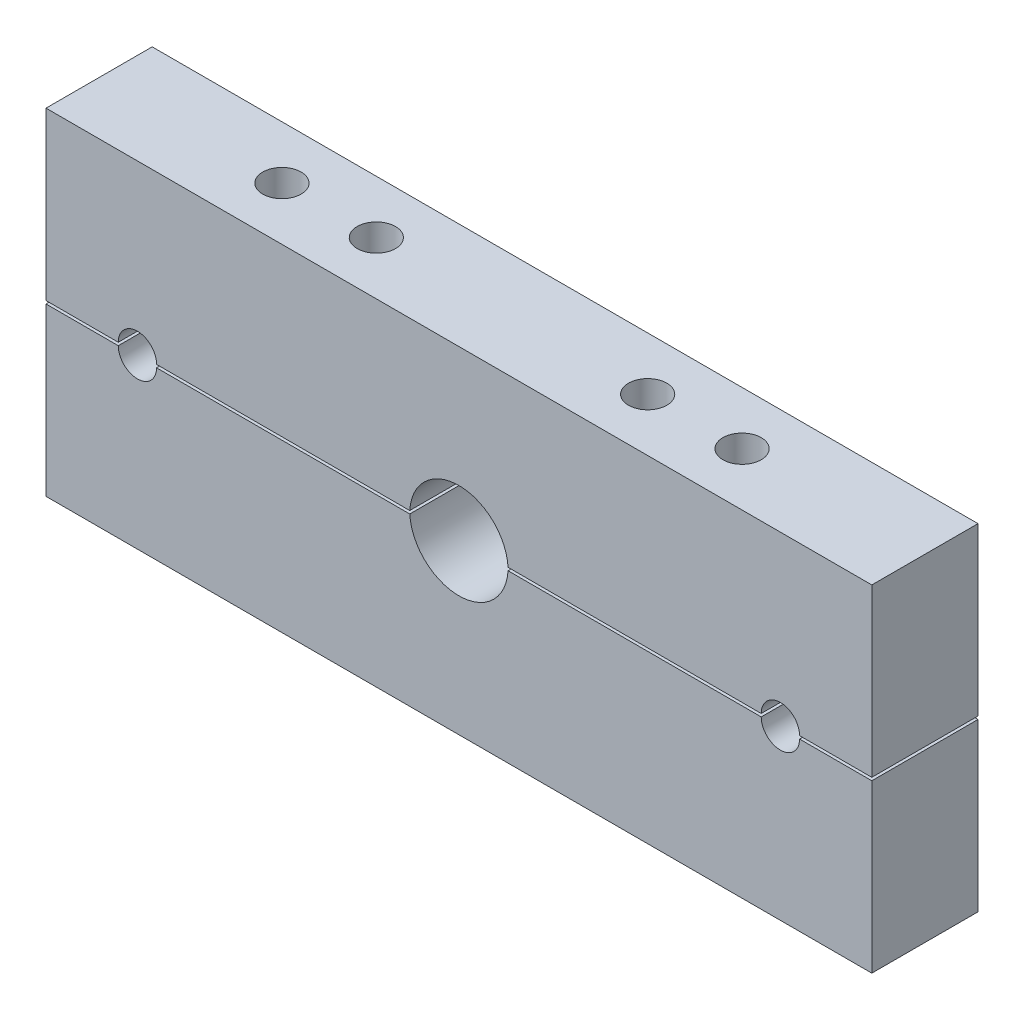
from build123d import *

# Parameters (mm, degrees)
BOSS_EXTRUDE1_DEPTH = 36
SKETCH2_W           = 36
SKETCH2_H           = 0.5
CUT_EXTRUDE1_DEPTH  = 281
SKETCH4_R           = 6.5
CUT_EXTRUDE3_DEPTH  = 58
SKETCH5_W           = 36
SKETCH5_H           = 0.5
CUT_EXTRUDE4_DEPTH  = 281
CUT_EXTRUDE5_DEPTH  = 37


with BuildPart() as part:
    # Sketch1 → Boss-Extrude1 (new body)
    with BuildSketch(Plane.XY):
        with BuildLine():
            Line((267.829500207, -84.51965646), (-12.170499793, -84.51965646))
            Line((-12.170499793, -84.51965646), (-12.170499793, -142.01965646))
            Line((-12.170499793, -142.01965646), (111.129500207, -142.01965646))
            ThreePointArc((111.129500207, -142.01965646), (127.829500207, -125.31965646), (144.529500207, -142.01965646))
            Line((144.529500207, -142.01965646), (267.829500207, -142.01965646))
            Line((267.829500207, -142.01965646), (267.829500207, -84.51965646))
        make_face()
    boss_extrude1 = extrude(amount=BOSS_EXTRUDE1_DEPTH)

    # Sketch2 → Cut-Extrude1 (cut, through all)
    with BuildSketch(Plane.ZY.offset(12.170499793)):
        with Locations((18, -141.76965646)):
            Rectangle(SKETCH2_W, SKETCH2_H)
    cut_extrude1 = extrude(amount=-CUT_EXTRUDE1_DEPTH, mode=Mode.SUBTRACT)

    # Sketch4 → Cut-Extrude3 (cut, through all)
    with BuildSketch(Plane(origin=(0, -84.51965646, 0), x_dir=(1, 0, 0), z_dir=(0, 1, 0))):
        with Locations((205.829500207, -18)):
            Circle(SKETCH4_R)
        with Locations((173.829500207, -18)):
            Circle(SKETCH4_R)
        with Locations((81.829500207, -18)):
            Circle(SKETCH4_R)
        with Locations((49.829500207, -18)):
            Circle(SKETCH4_R)
    cut_extrude3 = extrude(amount=-CUT_EXTRUDE3_DEPTH, mode=Mode.SUBTRACT)

    # Mirror1: Boss-Extrude1, Cut-Extrude1, Cut-Extrude3 across plane
    add(boss_extrude1.mirror(Plane(origin=(267.829500207, -141.51965646, 0), x_dir=(0, 0, 1), z_dir=(0, 1, 0))))
    add(cut_extrude1.mirror(Plane(origin=(267.829500207, -141.51965646, 0), x_dir=(0, 0, 1), z_dir=(0, 1, 0))), mode=Mode.SUBTRACT)
    add(cut_extrude3.mirror(Plane(origin=(267.829500207, -141.51965646, 0), x_dir=(0, 0, 1), z_dir=(0, 1, 0))), mode=Mode.SUBTRACT)

    # Sketch5 → Cut-Extrude4 (cut, through all)
    with BuildSketch(Plane.ZY.offset(12.170499793)):
        with Locations((18, -141.76965646)):
            Rectangle(SKETCH5_W, SKETCH5_H)
    extrude(amount=-CUT_EXTRUDE4_DEPTH, mode=Mode.SUBTRACT)

    # Sketch3 → Cut-Extrude5 (cut, through all)
    with BuildSketch(Plane.XY.offset(36)):
        with BuildLine():
            ThreePointArc((25.329500207, -141.01965646), (18.829500207, -134.51965646), (12.329500207, -141.01965646))
            Line((12.329500207, -141.01965646), (25.329500207, -141.01965646))
        make_face()
        with BuildLine():
            ThreePointArc((243.329500207, -141.01965646), (236.829500207, -134.51965646), (230.329500207, -141.01965646))
            Line((230.329500207, -141.01965646), (243.329500207, -141.01965646))
        make_face()
        with BuildLine():
            Line((12.329500207, -142.01965646), (25.329500207, -142.01965646))
            ThreePointArc((25.329500207, -142.01965646), (18.829500207, -148.51965646), (12.329500207, -142.01965646))
        make_face()
        with BuildLine():
            Line((230.329500207, -142.01965646), (243.329500207, -142.01965646))
            ThreePointArc((243.329500207, -142.01965646), (236.829500207, -148.51965646), (230.329500207, -142.01965646))
        make_face()
    extrude(amount=-CUT_EXTRUDE5_DEPTH, mode=Mode.SUBTRACT)


solid = part.part
